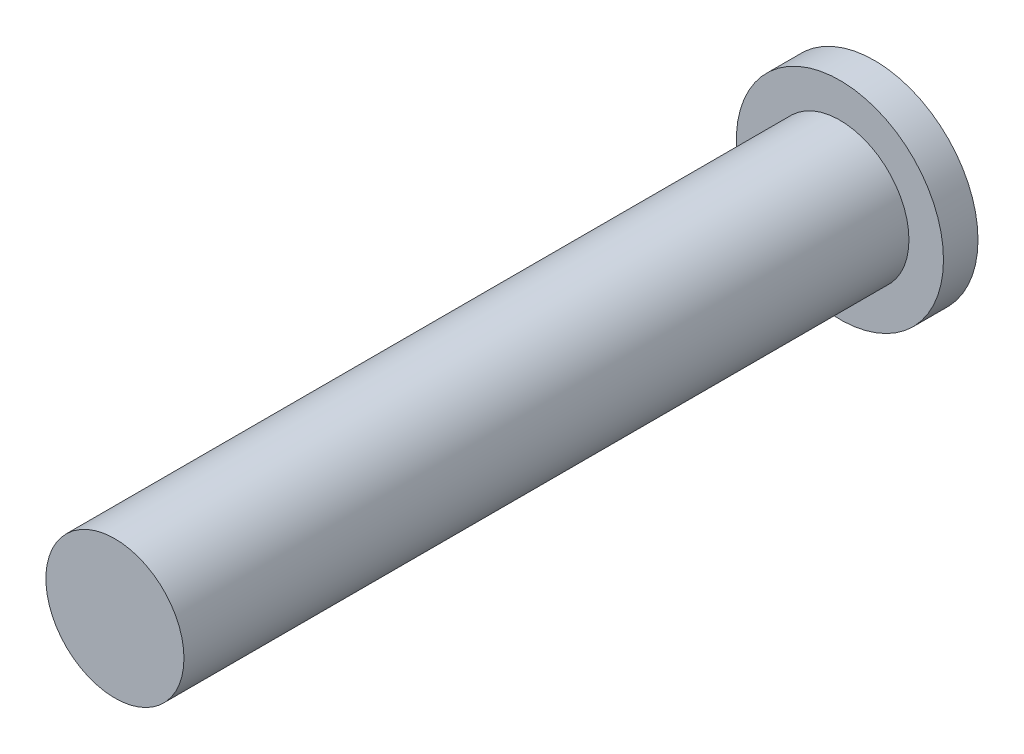
from build123d import *

# Parameters (mm, degrees)
ESQUISSE1_R        = 2
BOSS_EXTRU_1_DEPTH = 21
ESQUISSE1_3_R      = 3
BOSS_EXTRU_2_DEPTH = 1


with BuildPart() as part:
    # Esquisse1 → Boss.-Extru.1 (new body)
    with BuildSketch(Plane.XY):
        Circle(ESQUISSE1_R)
    extrude(amount=BOSS_EXTRU_1_DEPTH)

    # Esquisse1_3 → Boss.-Extru.2 (add)
    with BuildSketch(Plane.XY):
        Circle(ESQUISSE1_3_R)
    extrude(amount=-BOSS_EXTRU_2_DEPTH)


solid = part.part
